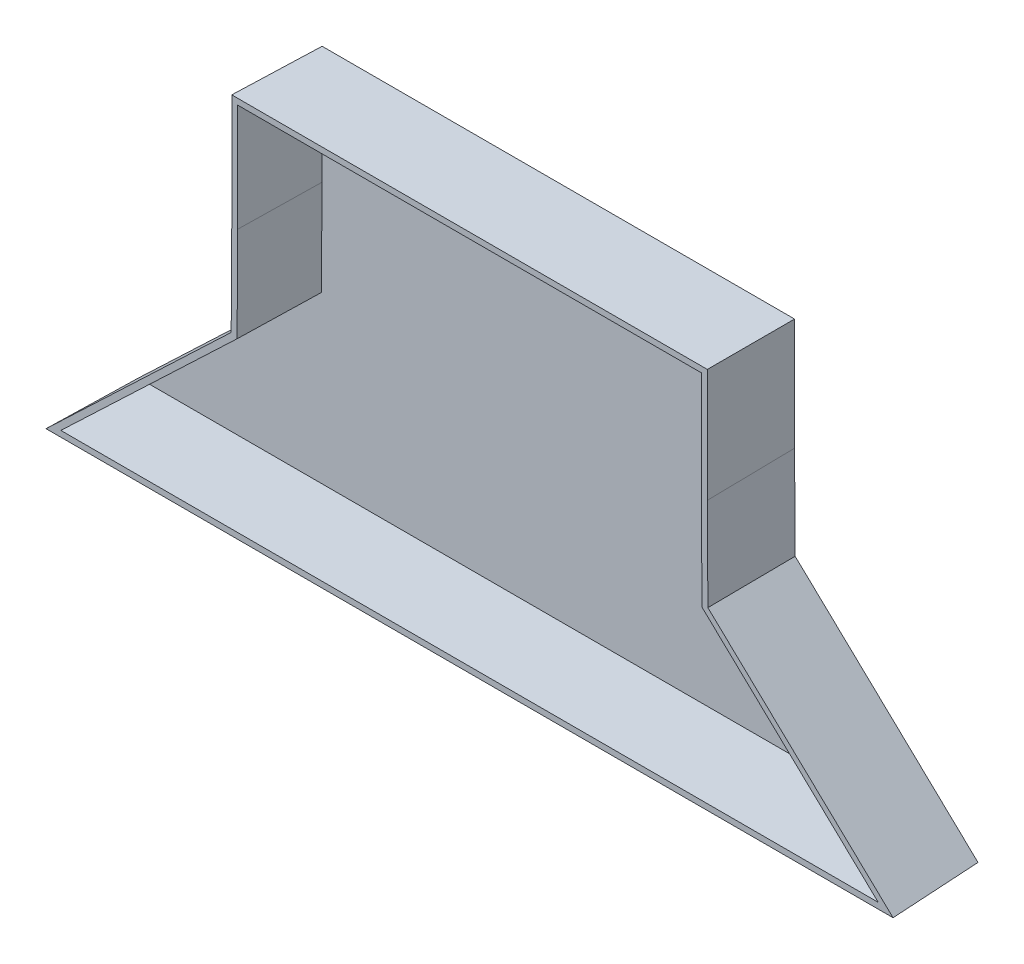
from build123d import *

# Parameters (mm, degrees)
BOSS_EXTRUDE1_DEPTH = 15
BOSS_EXTRUDE1_DRAFT = -1
SHELL1_T            = -1


with BuildPart() as part:
    # Sketch4 → Boss-Extrude1 (with draft: the straight prism first)
    with BuildSketch(Plane.XY):
        Polygon((134.568658859, 69.541396533), (54.766431957, 69.541396533), (54.766431957, 50.647773961), (54.667545408, 34.886919054), (23.782154036, 5.541396533), (165.55293678, 5.541396533), (134.667545408, 34.886919054), (134.568658859, 50.647773961), align=None)
    extrude(amount=BOSS_EXTRUDE1_DEPTH)
    # Boss-Extrude1: the draft: its side faces are tilted about the plane it starts from
    boss_extrude1_sides = [part.faces().sort_by_distance(p)[0] for p in [
        (94.667545408, 69.541396533, 7.5),
        (54.766431957, 60.094585247, 7.5),
        (54.716988683, 42.767346508, 7.5),
        (39.224849722, 20.214157793, 7.5),
        (94.667545408, 5.541396533, 7.5),
        (150.110241094, 20.214157793, 7.5),
        (134.618102134, 42.767346508, 7.5),
        (134.568658859, 60.094585247, 7.5),
    ]]
    draft(boss_extrude1_sides, Plane.XY, BOSS_EXTRUDE1_DRAFT)

    # Shell1
    shell1_openings = [part.faces().sort_by_distance(p)[0] for p in [
        (94.667545408, 34.129623645, 15),
    ]]
    offset(amount=SHELL1_T, openings=shell1_openings, kind=Kind.INTERSECTION)


solid = part.part
